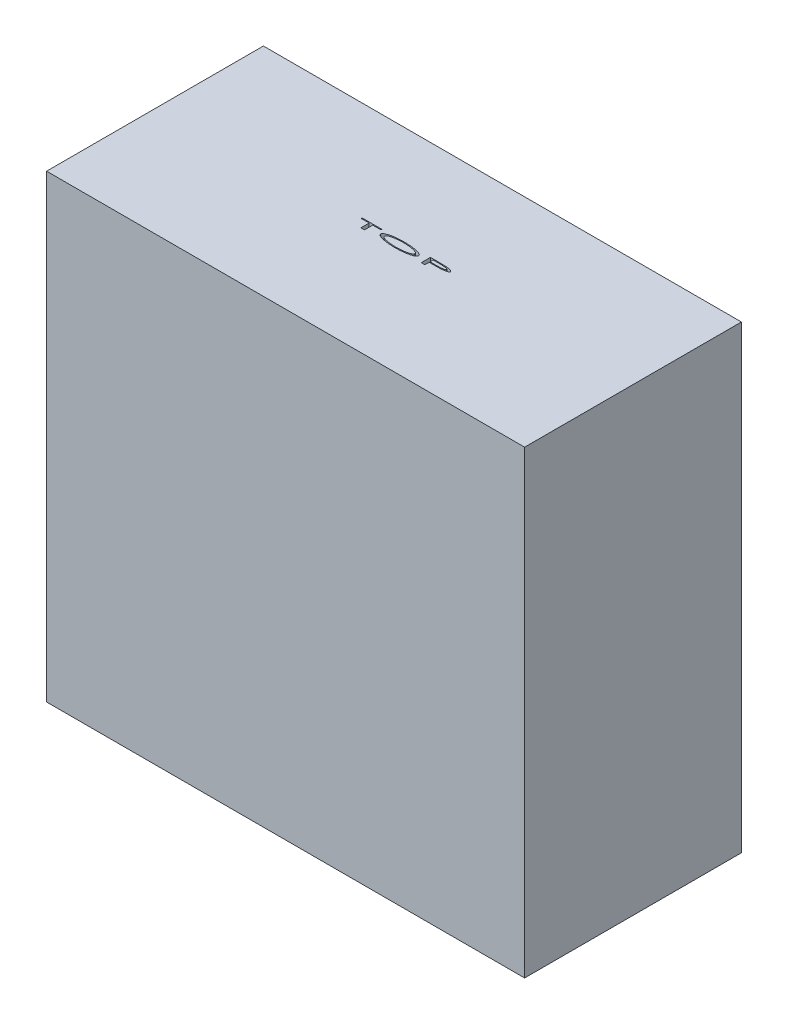
from build123d import *

# Parameters (mm, degrees)
SKETCH1_W           = 183
SKETCH1_H           = 83
BOSS_EXTRUDE1_DEPTH = 176
CUT_EXTRUDE1_DEPTH  = 5


with BuildPart() as part:
    # Sketch1 → Boss-Extrude1 (new body)
    with BuildSketch(Plane(origin=(0, 0, 0), x_dir=(1, 0, 0), z_dir=(0, 1, 0))):
        Rectangle(SKETCH1_W, SKETCH1_H)
    extrude(amount=BOSS_EXTRUDE1_DEPTH)

    # Sketch5 → Cut-Extrude1 (cut)
    with BuildSketch(Plane(origin=(0, 176, 0), x_dir=(1, 0, 0), z_dir=(0, 1, 0))):
        Polygon((-15.659468789, 3.042423349), (-15.659468789, 3.401397708), (-8.076135455, 3.401397708), (-8.076135455, 3.042423349), (-11.172289302, 3.042423349), (-11.172289302, -0.098602292), (-12.563314943, -0.098602292), (-12.563314943, 3.042423349), align=None)
        with BuildLine():
            add(Edge.make_bspline(
                [(0.427770795, 3.491141297), (0.55677959, 3.490740405), (0.812008304, 3.489947287), (1.190876739, 3.48353622), (1.561542542, 3.472809799), (1.92432336, 3.459297134), (2.279106132, 3.440164931), (2.625933084, 3.416956619), (2.964865913, 3.390466324), (3.295893008, 3.359932214), (3.618823318, 3.323799841), (3.933960157, 3.284826222), (4.240873501, 3.241409708), (4.539834436, 3.19373819), (4.830859884, 3.141901152), (5.113963725, 3.08595097), (5.389103004, 3.025659548), (5.654830513, 2.961398211), (5.908638202, 2.894926803), (6.147193062, 2.825268744), (6.369571442, 2.755022736), (6.57534492, 2.682039923), (6.764786272, 2.60751122), (6.937499907, 2.530198899), (7.094289532, 2.452268411), (7.234377913, 2.371578719), (7.358375512, 2.28904709), (7.466014358, 2.204430942), (7.557603602, 2.118185261), (7.632135596, 2.02930704), (7.690631122, 1.938278382), (7.732626577, 1.845097836), (7.758576706, 1.749543667), (7.761934929, 1.684972143), (7.763608134, 1.652799951)],
                knots=[0, 0, 0, 0, 0.000387025, 0.000765683, 0.001136726, 0.001499477, 0.001854749, 0.002202575, 0.002542263, 0.002874627, 0.003199816, 0.003517059, 0.003827212, 0.004129671, 0.004425226, 0.004713979, 0.004995355, 0.00527016, 0.005534095, 0.005782376, 0.00601564, 0.006233626, 0.006437252, 0.006626186, 0.006801148, 0.006962293, 0.007110858, 0.007247622, 0.007372591, 0.007487585, 0.007594756, 0.007696128, 0.007793231, 0.007889652, 0.007889652, 0.007889652, 0.007889652], degree=3))
            add(Edge.make_bspline(
                [(7.763608134, 1.652799951), (7.761949849, 1.620853956), (7.758621135, 1.556728026), (7.73245398, 1.462058113), (7.691447928, 1.369263532), (7.632840635, 1.278823659), (7.557323933, 1.191377988), (7.467069301, 1.104540424), (7.359405052, 1.020691756), (7.235847323, 0.938117827), (7.09560466, 0.857940884), (6.939884378, 0.778295054), (6.766643059, 0.702959372), (6.578246051, 0.626464633), (6.372237165, 0.554734656), (6.151035559, 0.481872028), (5.91269203, 0.413082669), (5.659769872, 0.345544851), (5.395034729, 0.280499068), (5.121309976, 0.220786579), (4.84101167, 0.16345205), (4.553082743, 0.112085133), (4.258169704, 0.063574352), (3.955987943, 0.019233773), (3.646398752, -0.019559539), (3.32974587, -0.055553262), (3.005770948, -0.086897236), (2.674842899, -0.114527867), (2.336568137, -0.136434569), (1.991152458, -0.155622109), (1.638451822, -0.170231094), (1.278749758, -0.180671389), (0.911802676, -0.187166446), (0.664752636, -0.187950036), (0.539950282, -0.188345882)],
                knots=[0, 0, 0, 0, 9.5723e-05, 0.000192147, 0.000292594, 0.000399173, 0.000514082, 0.000638545, 0.000774324, 0.000922889, 0.001084034, 0.001258687, 0.001447335, 0.00165057, 0.001868556, 0.002101582, 0.002349191, 0.002612628, 0.002886917, 0.003166924, 0.003453065, 0.003745169, 0.00404428, 0.004349674, 0.004661352, 0.00498027, 0.005305721, 0.005637778, 0.005976463, 0.006322634, 0.006675605, 0.007035435, 0.007402176, 0.007776581, 0.007776581, 0.007776581, 0.007776581], degree=3))
            add(Edge.make_bspline(
                [(0.539950282, -0.188345882), (0.413745616, -0.187950573), (0.16365746, -0.187167225), (-0.207728183, -0.180653217), (-0.571643516, -0.170334556), (-0.928047051, -0.15529267), (-1.277055224, -0.137618461), (-1.618518555, -0.114319195), (-1.952468119, -0.08670699), (-2.279106352, -0.056526747), (-2.598037806, -0.02017791), (-2.909749265, 0.018459732), (-3.213723023, 0.063054296), (-3.510634897, 0.110531164), (-3.800136925, 0.162051128), (-4.081869008, 0.219244757), (-4.356401456, 0.279272438), (-4.621915149, 0.343473604), (-4.87567362, 0.410090644), (-5.114256749, 0.479178249), (-5.335829078, 0.551148084), (-5.541910018, 0.622555006), (-5.730972346, 0.697596446), (-5.903862908, 0.773973846), (-6.060659504, 0.851208788), (-6.200512434, 0.931313587), (-6.324707282, 1.012323804), (-6.432304818, 1.095580103), (-6.523938978, 1.180369349), (-6.59822754, 1.267771119), (-6.656967234, 1.356733639), (-6.698958592, 1.447834794), (-6.724948604, 1.541300312), (-6.72830833, 1.604498021), (-6.729981609, 1.635973028)],
                knots=[0, 0, 0, 0, 0.000378612, 0.00075026, 0.001114294, 0.001470768, 0.001820402, 0.002162631, 0.002497484, 0.00282566, 0.003146668, 0.003460432, 0.003767908, 0.00406829, 0.004362465, 0.004649981, 0.004930672, 0.005205477, 0.005469412, 0.005717693, 0.005950503, 0.006168256, 0.006371882, 0.00656053, 0.006735179, 0.006895974, 0.007043763, 0.007179661, 0.007303667, 0.007417588, 0.007522989, 0.007622445, 0.007717514, 0.00781184, 0.00781184, 0.00781184, 0.00781184], degree=3))
            add(Edge.make_bspline(
                [(-6.729981609, 1.635973028), (-6.72937583, 1.657060051), (-6.728168949, 1.699071261), (-6.716207634, 1.76165511), (-6.697360326, 1.823576356), (-6.670067323, 1.884825418), (-6.636588154, 1.945771431), (-6.595283692, 2.006124902), (-6.546015088, 2.065259629), (-6.489746301, 2.124490865), (-6.425645205, 2.182358951), (-6.354583919, 2.240376223), (-6.275049749, 2.2965429), (-6.188964575, 2.353457599), (-6.095404384, 2.409607722), (-5.994308238, 2.464914368), (-5.88554065, 2.519573776), (-5.7693801, 2.573159684), (-5.646947629, 2.62637213), (-5.518920722, 2.678276222), (-5.385144271, 2.727732184), (-5.246613714, 2.777280968), (-5.101807844, 2.82368743), (-4.952223962, 2.870292843), (-4.796678594, 2.914380096), (-4.63581656, 2.956961243), (-4.469621642, 2.998287048), (-4.298101412, 3.038430483), (-4.121111037, 3.07673834), (-3.938592119, 3.11400848), (-3.750652328, 3.149634058), (-3.55721311, 3.184273806), (-3.358142133, 3.215935462), (-3.08457637, 3.25870382), (-2.735101617, 3.306477501), (-2.308179758, 3.355230418), (-1.872979728, 3.397468614), (-1.429078018, 3.431658289), (-0.976780335, 3.458362355), (-0.516056293, 3.476799977), (-0.046960829, 3.48956063), (0.268607459, 3.490611347), (0.427770795, 3.491141297)],
                knots=[0, 0, 0, 0, 6.3198e-05, 0.000125909, 0.000190446, 0.000257008, 0.000326674, 0.000398821, 0.000476024, 0.000557354, 0.000643709, 0.000734922, 0.000832401, 0.000935659, 0.001044477, 0.001159634, 0.001281293, 0.00140959, 0.001543358, 0.001681756, 0.001823966, 0.001971208, 0.002123087, 0.0022801, 0.002441221, 0.002608054, 0.002779292, 0.002954971, 0.003136498, 0.003322539, 0.003513812, 0.003710347, 0.003912061, 0.004118512, 0.004541012, 0.00497011, 0.005407534, 0.005852672, 0.006305679, 0.006766705, 0.007235907, 0.007713384, 0.007713384, 0.007713384, 0.007713384], degree=3))
        make_face()
        with BuildLine():
            add(Edge.make_bspline(
                [(0.488768391, 3.132166938), (0.362792774, 3.131761549), (0.112204333, 3.130955154), (-0.261061033, 3.120388832), (-0.629449739, 3.105308433), (-0.992965516, 3.08379139), (-1.351467662, 3.054683215), (-1.705171733, 3.020608845), (-2.053703624, 2.979959646), (-2.39493417, 2.933142404), (-2.724453202, 2.88217684), (-3.037416855, 2.825231342), (-3.331825877, 2.764578283), (-3.607561797, 2.699622596), (-3.864553096, 2.63022698), (-4.10319997, 2.557283972), (-4.322941376, 2.47849966), (-4.493752622, 2.409265581), (-4.619570872, 2.350637761), (-4.70690995, 2.308530438), (-4.787268967, 2.263771917), (-4.862789064, 2.220222727), (-4.931176635, 2.174425568), (-4.994060432, 2.128825148), (-5.051008622, 2.082547148), (-5.102051126, 2.035734059), (-5.147662864, 1.98871278), (-5.186214879, 1.940059739), (-5.219173105, 1.891003208), (-5.247018096, 1.841812384), (-5.268318719, 1.791733256), (-5.2828871, 1.740835383), (-5.29266561, 1.68940025), (-5.293611405, 1.654713775), (-5.294084173, 1.637375272)],
                knots=[0, 0, 0, 0, 0.000377915, 0.000751742, 0.001120154, 0.001483985, 0.001844108, 0.00219914, 0.002549962, 0.002896708, 0.003232373, 0.003550188, 0.003850911, 0.004134062, 0.004399894, 0.004649384, 0.004882462, 0.005100027, 0.00520198, 0.005298869, 0.005390804, 0.005477862, 0.005560312, 0.005637582, 0.005710838, 0.005780309, 0.005845272, 0.005907138, 0.005966253, 0.006022434, 0.006076475, 0.006129059, 0.006181047, 0.006233005, 0.006233005, 0.006233005, 0.006233005], degree=3))
            add(Edge.make_bspline(
                [(-5.294084173, 1.637375272), (-5.292978789, 1.611759682), (-5.290752968, 1.560179685), (-5.268943465, 1.484483275), (-5.235384183, 1.410367623), (-5.188586664, 1.337896059), (-5.128008759, 1.267466866), (-5.054165869, 1.198836351), (-4.968081293, 1.130626726), (-4.86742728, 1.066143657), (-4.754972644, 1.001165808), (-4.628849401, 0.938556731), (-4.489320162, 0.877861169), (-4.337324242, 0.817337294), (-4.171500702, 0.759588245), (-3.992627612, 0.702837772), (-3.800395783, 0.647649182), (-3.596347651, 0.593985604), (-3.382781245, 0.5434116), (-3.162685649, 0.494837496), (-2.936868908, 0.449983492), (-2.705586241, 0.409033517), (-2.4692047, 0.369878048), (-2.227121366, 0.336146279), (-1.97990291, 0.304278645), (-1.727173995, 0.276556683), (-1.469183203, 0.251074517), (-1.205519349, 0.229471244), (-0.936263558, 0.21118871), (-0.661607051, 0.196782935), (-0.381627063, 0.184599385), (-0.096241962, 0.176346303), (0.194511914, 0.171266371), (0.390141806, 0.170842281), (0.488768391, 0.170628477)],
                knots=[0, 0, 0, 0, 7.6682e-05, 0.000154409, 0.000234426, 0.000320195, 0.000412213, 0.000512403, 0.000622231, 0.000741242, 0.000870644, 0.001011742, 0.001163374, 0.00132703, 0.00150243, 0.001690019, 0.001889951, 0.002102355, 0.002322919, 0.002548324, 0.002778502, 0.003013541, 0.003252945, 0.003497259, 0.003746758, 0.004000715, 0.00425996, 0.004524476, 0.004794323, 0.005069557, 0.005349558, 0.005635039, 0.005926046, 0.006221923, 0.006221923, 0.006221923, 0.006221923], degree=3))
            add(Edge.make_bspline(
                [(0.488768391, 0.170628477), (0.620584618, 0.171107648), (0.881912291, 0.172057612), (1.270155681, 0.181453194), (1.651159598, 0.196707042), (2.024662472, 0.218540893), (2.390689845, 0.245924925), (2.749135667, 0.278286843), (3.099883195, 0.318829989), (3.441504241, 0.363603157), (3.770111593, 0.414737912), (4.082120662, 0.469527947), (4.375469279, 0.529949059), (4.650263945, 0.594146435), (4.906539451, 0.662388862), (5.1436512, 0.736006581), (5.362421653, 0.81341598), (5.531821132, 0.883521042), (5.657507656, 0.941203491), (5.743590711, 0.984848584), (5.824210049, 1.028097318), (5.898172903, 1.073234672), (5.967130989, 1.117725485), (6.029729264, 1.163259357), (6.086046254, 1.209992984), (6.137115715, 1.256279704), (6.182013456, 1.303782833), (6.220270983, 1.352152301), (6.253850996, 1.400463371), (6.280476291, 1.449988841), (6.301999702, 1.499813469), (6.316499511, 1.550750189), (6.326251617, 1.601944815), (6.327226631, 1.63639668), (6.327710698, 1.653501073)],
                knots=[0, 0, 0, 0, 0.000395443, 0.000783971, 0.001164993, 0.001539322, 0.001906328, 0.002266113, 0.002618945, 0.002965504, 0.003299675, 0.003616552, 0.00391576, 0.004198067, 0.00446304, 0.004711191, 0.004942712, 0.005158982, 0.005260934, 0.005357508, 0.005448492, 0.005535307, 0.005617371, 0.005694641, 0.005767355, 0.005836826, 0.005901307, 0.005963172, 0.006021707, 0.00607755, 0.006131591, 0.006184176, 0.006236163, 0.006287421, 0.006287421, 0.006287421, 0.006287421], degree=3))
            add(Edge.make_bspline(
                [(6.327710698, 1.653501073), (6.327244933, 1.670608804), (6.326313054, 1.704837063), (6.316382152, 1.755759786), (6.302136346, 1.806306314), (6.2804795, 1.855639093), (6.253620709, 1.904530618), (6.220525652, 1.952713899), (6.181729047, 2.000414896), (6.137360262, 2.047938509), (6.085987119, 2.093464868), (6.029717346, 2.139543762), (5.96710477, 2.184359606), (5.898156889, 2.228149951), (5.824190157, 2.272589872), (5.743574129, 2.315129592), (5.657489592, 2.358074132), (5.531794624, 2.414823957), (5.361867706, 2.483857421), (5.14203777, 2.560632584), (4.902880982, 2.633160972), (4.644240856, 2.701879333), (4.366332826, 2.765801902), (4.068975846, 2.82620872), (3.752373671, 2.8819105), (3.418525488, 2.933267082), (3.072594885, 2.979923059), (2.718933963, 3.020664671), (2.360078763, 3.054627854), (1.995977184, 3.083857508), (1.626614197, 3.105295451), (1.25191771, 3.120390315), (0.872108941, 3.130960296), (0.617080959, 3.131763048), (0.488768391, 3.132166938)],
                knots=[0, 0, 0, 0, 5.1259e-05, 0.000102556, 0.00015514, 0.000208536, 0.000263764, 0.000322299, 0.000383618, 0.000448098, 0.000517097, 0.000589367, 0.000666225, 0.000747908, 0.000834363, 0.000925014, 0.001021274, 0.001122935, 0.001338672, 0.001571281, 0.001821235, 0.00208824, 0.002373962, 0.002676604, 0.002998436, 0.003338257, 0.003689867, 0.004045565, 0.004406179, 0.004771195, 0.005141325, 0.005516042, 0.005896176, 0.006281102, 0.006281102, 0.006281102, 0.006281102], degree=3))
        make_face(mode=Mode.SUBTRACT)
        with BuildLine():
            Line((10.545659416, 3.401397708), (13.277931051, 3.401397708))
            add(Edge.make_bspline(
                [(13.277931051, 3.401397708), (13.373751048, 3.401445665), (13.561652022, 3.401539708), (13.837427875, 3.400865746), (14.101515857, 3.399329794), (14.353450683, 3.397787606), (14.593478786, 3.397042893), (14.821560905, 3.393325444), (15.037760224, 3.392139017), (15.2420077, 3.388084978), (15.434115528, 3.38465724), (15.61431432, 3.381356984), (15.782584187, 3.377087068), (15.938947782, 3.37243011), (16.083338001, 3.366199508), (16.215916555, 3.362137068), (16.336474537, 3.355399444), (16.412881531, 3.350931675), (16.449104929, 3.348813573)],
                knots=[0, 0, 0, 0, 0.00028746, 0.000563703, 0.000827328, 0.001079736, 0.001319524, 0.001547406, 0.001764063, 0.001968119, 0.002160258, 0.002340481, 0.002508803, 0.00266523, 0.00280977, 0.002942373, 0.003063131, 0.003171987, 0.003171987, 0.003171987, 0.003171987], degree=3))
            add(Edge.make_bspline(
                [(16.449104929, 3.348813573), (16.544724368, 3.342223921), (16.731917412, 3.329323436), (17.005660977, 3.303317245), (17.266106586, 3.272629847), (17.513017986, 3.237023384), (17.746621225, 3.196495771), (17.966739225, 3.151237591), (18.173461187, 3.100662075), (18.336613173, 3.054375847), (18.458979043, 3.014781324), (18.543490101, 2.984292577), (18.62263903, 2.954040211), (18.695452009, 2.921599463), (18.762601053, 2.888828887), (18.823289303, 2.854224474), (18.879215776, 2.820110569), (18.929153277, 2.784558166), (18.972698084, 2.747158973), (19.010851463, 2.709333294), (19.043285216, 2.670638805), (19.070472495, 2.631295921), (19.091047089, 2.590455281), (19.104770169, 2.548523911), (19.114843388, 2.506071374), (19.11572753, 2.477145049), (19.116172237, 2.462595624)],
                knots=[0, 0, 0, 0, 0.000287529, 0.000562892, 0.000824832, 0.001074203, 0.001311192, 0.001536012, 0.001748233, 0.001949513, 0.002044631, 0.002134004, 0.002219025, 0.002298756, 0.002373068, 0.002443075, 0.002508253, 0.002569544, 0.002626732, 0.002680275, 0.002730546, 0.002777995, 0.00282346, 0.002867138, 0.002910181, 0.002953741, 0.002953741, 0.002953741, 0.002953741], degree=3))
            add(Edge.make_bspline(
                [(19.116172237, 2.462595624), (19.11563444, 2.448064174), (19.114558497, 2.418991865), (19.105786395, 2.376098511), (19.09177674, 2.333980237), (19.070791531, 2.29352627), (19.045858375, 2.252948445), (19.013527839, 2.214813654), (18.977236071, 2.176297782), (18.933945387, 2.140437372), (18.886052821, 2.104182406), (18.83210849, 2.06936895), (18.772205792, 2.035834138), (18.706897584, 2.002948313), (18.636150196, 1.970610316), (18.559279536, 1.939886807), (18.477006572, 1.909859192), (18.357179511, 1.870834193), (18.195953455, 1.824791362), (17.988781501, 1.774276363), (17.764414917, 1.729128227), (17.523086538, 1.688596829), (17.264662013, 1.653229165), (16.989080523, 1.621630198), (16.696130302, 1.595202027), (16.494939962, 1.581375379), (16.391612942, 1.57427431)],
                knots=[0, 0, 0, 0, 4.356e-05, 8.7148e-05, 0.000130826, 0.000176291, 0.000223558, 0.000273383, 0.000325943, 0.000382143, 0.000441738, 0.000506108, 0.000574549, 0.000647607, 0.000725419, 0.000807833, 0.000895887, 0.000988121, 0.001185839, 0.001398741, 0.001627681, 0.001872272, 0.00213275, 0.002410092, 0.002704369, 0.003015076, 0.003015076, 0.003015076, 0.003015076], degree=3))
            add(Edge.make_bspline(
                [(16.391612942, 1.57427431), (16.35071954, 1.571834342), (16.26475108, 1.566704902), (16.12940042, 1.560781778), (15.981482728, 1.55422246), (15.820917069, 1.548697474), (15.647725372, 1.544031044), (15.461938798, 1.538903551), (15.26351698, 1.534745094), (15.052470569, 1.531496753), (14.828819948, 1.527690196), (14.592533966, 1.52522356), (14.343640911, 1.522160076), (14.082120255, 1.52010142), (13.807745221, 1.518930599), (13.520754549, 1.517295075), (13.221140469, 1.516645554), (13.017347454, 1.51673611), (12.913347718, 1.516782323)],
                knots=[0, 0, 0, 0, 0.000122896, 0.00025836, 0.000406431, 0.000567086, 0.000740333, 0.000926195, 0.001124657, 0.001335724, 0.001559409, 0.001795704, 0.002044618, 0.002306145, 0.002580287, 0.00286775, 0.00316713, 0.003479129, 0.003479129, 0.003479129, 0.003479129], degree=3))
            Line((12.913347718, 1.516782323), (11.936685057, 1.516782323))
            Line((11.936685057, 1.516782323), (11.936685057, -0.098602292))
            Line((11.936685057, -0.098602292), (10.545659416, -0.098602292))
            Line((10.545659416, -0.098602292), (10.545659416, 3.401397708))
        make_face()
        with BuildLine():
            Line((11.936685057, 3.042423349), (11.936685057, 1.875756682))
            Line((11.936685057, 1.875756682), (14.243375763, 1.868044342))
            add(Edge.make_bspline(
                [(14.243375763, 1.868044342), (14.300634128, 1.867991691), (14.41328169, 1.867888107), (14.579448878, 1.868637138), (14.739775323, 1.869928478), (14.894015684, 1.872314232), (15.042429979, 1.874068639), (15.184979439, 1.877269612), (15.321960428, 1.879457835), (15.452809356, 1.884227622), (15.577865532, 1.888036697), (15.696802982, 1.893247), (15.810173444, 1.897911513), (15.91768266, 1.903536117), (16.019360354, 1.909716672), (16.114912781, 1.917000839), (16.204699669, 1.923736909), (16.315315125, 1.933907531), (16.445767128, 1.948674612), (16.595016219, 1.96779409), (16.735441108, 1.99053025), (16.867201633, 2.014627886), (16.990233339, 2.041946612), (17.104526886, 2.072144183), (17.210344157, 2.10411939), (17.307075795, 2.138254869), (17.393669231, 2.17412048), (17.469033108, 2.21202791), (17.533245977, 2.250418983), (17.586574516, 2.289319306), (17.628374105, 2.330079423), (17.657616393, 2.37275438), (17.677027102, 2.416384737), (17.679211568, 2.446523911), (17.680274801, 2.461193381)],
                knots=[0, 0, 0, 0, 0.000171775, 0.000337942, 0.000498505, 0.000652766, 0.000800718, 0.000943774, 0.001080522, 0.001211699, 0.00133657, 0.001455861, 0.001568849, 0.001676967, 0.001778825, 0.001874435, 0.001964452, 0.00204894, 0.002207663, 0.002358287, 0.002500294, 0.00263437, 0.002760076, 0.002878269, 0.002988942, 0.003091615, 0.003185889, 0.003269921, 0.003344471, 0.003410097, 0.003467606, 0.003518557, 0.003564777, 0.003608607, 0.003608607, 0.003608607, 0.003608607], degree=3))
            add(Edge.make_bspline(
                [(17.680274801, 2.461193381), (17.679241719, 2.475644276), (17.677132639, 2.505146376), (17.657373255, 2.547696459), (17.62834779, 2.589520253), (17.586533593, 2.629591931), (17.533005333, 2.667643485), (17.469245266, 2.706325803), (17.393447793, 2.743155014), (17.307307334, 2.779191425), (17.211428209, 2.813075833), (17.107675055, 2.845451737), (16.996471777, 2.874547745), (16.877874205, 2.901220386), (16.752110414, 2.925691663), (16.618591479, 2.947331131), (16.477848395, 2.966313878), (16.355194954, 2.978970745), (16.251491739, 2.989875649), (16.166520526, 2.995264463), (16.075720005, 3.003150999), (15.978649645, 3.008059708), (15.875617782, 3.014029636), (15.766464565, 3.018834968), (15.651229567, 3.022817698), (15.530184738, 3.027305536), (15.40303061, 3.030487815), (15.269829755, 3.034267544), (15.130534724, 3.036946911), (14.98516773, 3.03912656), (14.83371973, 3.040262913), (14.676204656, 3.041908933), (14.512607044, 3.042559704), (14.401595585, 3.042469371), (14.345038423, 3.042423349)],
                knots=[0, 0, 0, 0, 4.3135e-05, 8.8061e-05, 0.000138435, 0.00019545, 0.000260658, 0.000335208, 0.000418927, 0.000513201, 0.000615214, 0.000723876, 0.000839179, 0.000959943, 0.001088508, 0.001223483, 0.001365674, 0.001514487, 0.00159339, 0.00167846, 0.001769876, 0.001866793, 0.00197001, 0.002079495, 0.002194556, 0.002315923, 0.002442875, 0.002576134, 0.002715685, 0.002860833, 0.003012282, 0.00317004, 0.003333403, 0.003503075, 0.003503075, 0.003503075, 0.003503075], degree=3))
            Line((14.345038423, 3.042423349), (11.936685057, 3.042423349))
        make_face(mode=Mode.SUBTRACT)
    extrude(amount=-CUT_EXTRUDE1_DEPTH, mode=Mode.SUBTRACT)


solid = part.part
